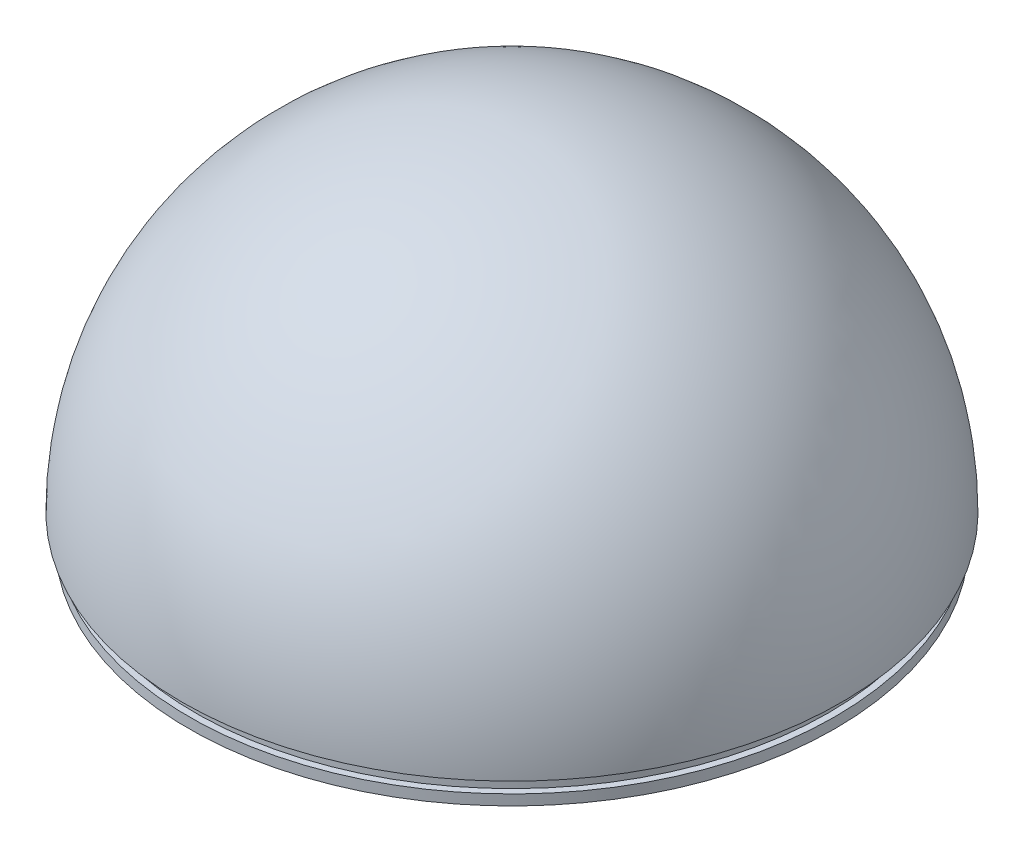
from build123d import *

# Parameters (mm, degrees)
REVOLVE1_ANGLE      = 180
SKETCH3_R           = 24.75
SKETCH3_R_2         = 23.25
BOSS_EXTRUDE2_DEPTH = 2
SKETCH4_R           = 24.75
SKETCH4_R_2         = 24.25
CUT_EXTRUDE1_DEPTH  = 1.2


with BuildPart() as part:
    # Sketch1 → Revolve1 (revolve)
    with BuildSketch(Plane(origin=(0, 0, 0), x_dir=(1, 0, 0), z_dir=(0, 1, 0))):
        with BuildLine():
            Line((0, 25.25), (0, 23.25))
            ThreePointArc((0, 23.25), (23.25, 0), (0, -23.25))
            Line((0, -23.25), (0, -25.25))
            ThreePointArc((0, -25.25), (25.25, 0), (0, 25.25))
        make_face()
    revolve(axis=Axis((0, 0, 23.25), (0, 0, 1)), revolution_arc=REVOLVE1_ANGLE)

    # Sketch3 → Boss-Extrude2 (add)
    with BuildSketch(Plane.XZ):
        Circle(SKETCH3_R)
        Circle(SKETCH3_R_2, mode=Mode.SUBTRACT)
    extrude(amount=BOSS_EXTRUDE2_DEPTH)

    # Sketch4 → Cut-Extrude1 (cut)
    with BuildSketch(Plane.XZ):
        Circle(SKETCH4_R)
        Circle(SKETCH4_R_2, mode=Mode.SUBTRACT)
    extrude(amount=CUT_EXTRUDE1_DEPTH, mode=Mode.SUBTRACT)


solid = part.part
